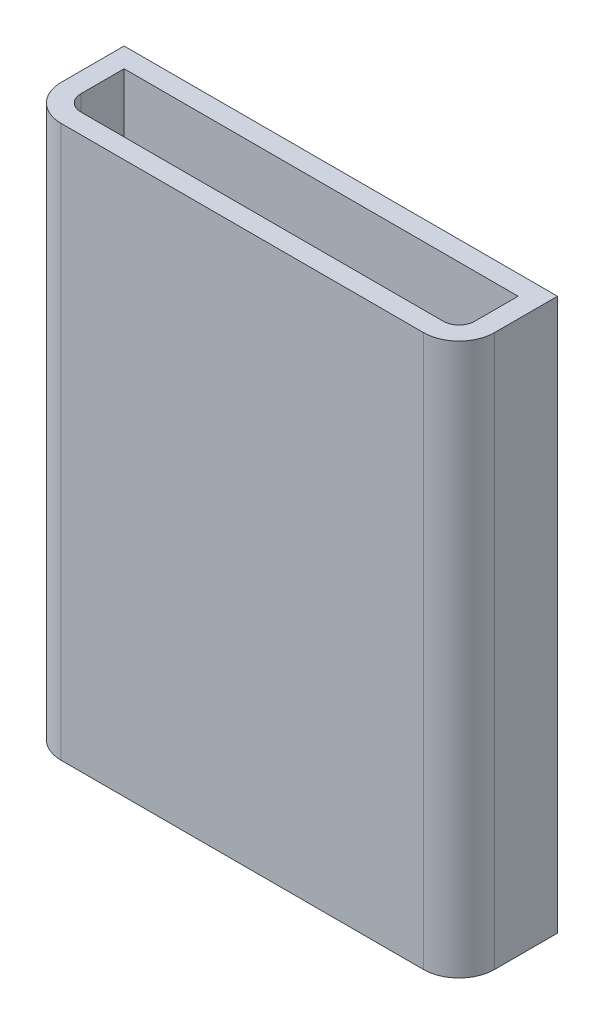
from build123d import *

# Parameters (mm, degrees)
BOSS_EXTRUDE1_DEPTH = 88.9
CUT_EXTRUDE1_DEPTH  = 88.9


with BuildPart() as part:
    # Sketch1 → Boss-Extrude1 (new body)
    with BuildSketch(Plane(origin=(0, 0, 0), x_dir=(1, 0, 0), z_dir=(0, 1, 0))):
        with BuildLine():
            Line((-3.175, 6.985), (-3.175, 2.54))
            ThreePointArc((-3.175, 2.54), (-1.501115254, -1.501115254), (2.54, -3.175))
            Line((2.54, -3.175), (60.96, -3.175))
            ThreePointArc((60.96, -3.175), (65.001115254, -1.501115254), (66.675, 2.54))
            Line((66.675, 2.54), (66.675, 6.985))
            Line((66.675, 6.985), (66.675, 12.7))
            Line((66.675, 12.7), (60.96, 12.7))
            Line((60.96, 12.7), (2.54, 12.7))
            Line((2.54, 12.7), (-3.175, 12.7))
            Line((-3.175, 12.7), (-3.175, 6.985))
        make_face()
    extrude(amount=BOSS_EXTRUDE1_DEPTH)

    # Sketch2 → Cut-Extrude1 (cut)
    with BuildSketch(Plane(origin=(0, 88.9, 0), x_dir=(1, 0, 0), z_dir=(0, 1, 0))):
        with BuildLine():
            Line((2.54, 9.525), (0, 9.525))
            Line((0, 9.525), (0, 6.985))
            Line((0, 6.985), (0, 2.54))
            ThreePointArc((0, 2.54), (0.743948776, 0.743948776), (2.54, 0))
            Line((2.54, 0), (60.96, 0))
            ThreePointArc((60.96, 0), (62.756051224, 0.743948776), (63.5, 2.54))
            Line((63.5, 2.54), (63.5, 6.985))
            Line((63.5, 6.985), (63.5, 9.525))
            Line((63.5, 9.525), (60.96, 9.525))
            Line((60.96, 9.525), (2.54, 9.525))
        make_face()
    extrude(amount=-CUT_EXTRUDE1_DEPTH, mode=Mode.SUBTRACT)


solid = part.part
